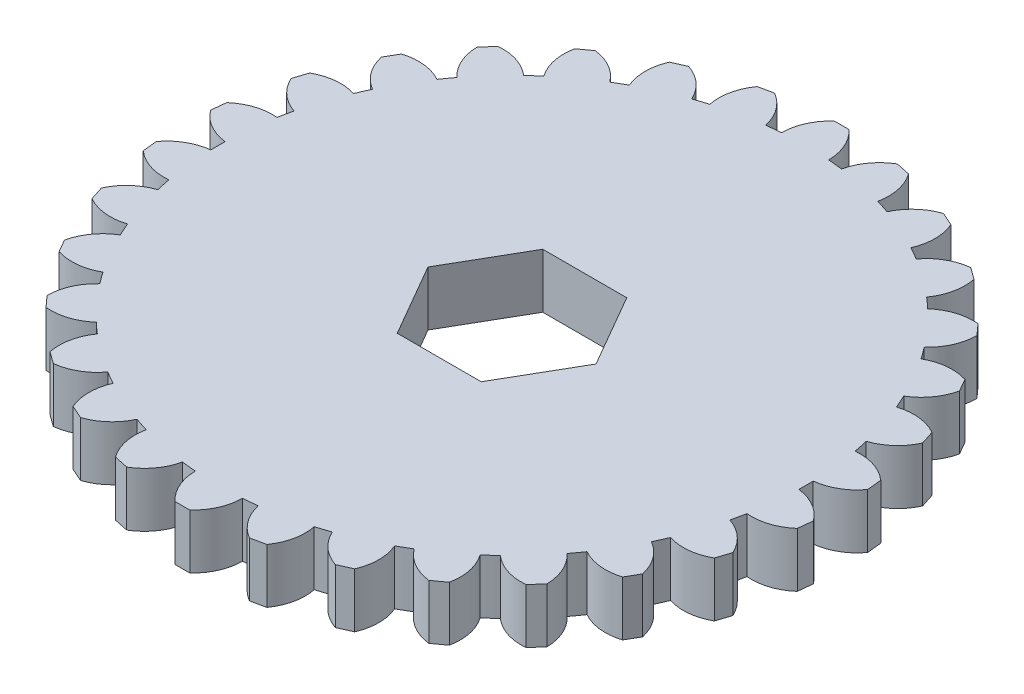
from build123d import *

# Parameters (mm, degrees)
SKETCH2_R           = 25.664173075
BOSS_EXTRUDE2_DEPTH = 4.7625
BOSS_EXTRUDE3_DEPTH = 4.7625
CIRPATTERN1_COUNT   = 30


with BuildPart() as part:
    # Sketch2 → Boss-Extrude2 (new body)
    with BuildSketch(Plane(origin=(0, 0, 0), x_dir=(1, 0, 0), z_dir=(0, 1, 0))):
        Circle(SKETCH2_R)
        Polygon((7.332348419, 0), (3.666174209, 6.35), (-3.666174209, 6.35), (-7.332348419, 0), (-3.666174209, -6.35), (3.666174209, -6.35), align=None, mode=Mode.SUBTRACT)
    extrude(amount=BOSS_EXTRUDE2_DEPTH)

    # Sketch1 → Boss-Extrude3 (add)
    with BuildSketch(Plane(origin=(0, 0, 0), x_dir=(1, 0, 0), z_dir=(0, 1, 0))):
        with BuildLine():
            Line((0.640211275, 28.764979636), (-0.640211275, 28.764979636))
            ThreePointArc((-0.640211275, 28.764979636), (-1.726312193, 27.213866774), (-2.055125292, 25.349075026))
            ThreePointArc((-2.055125292, 25.349075026), (0, 25.432246157), (2.055125292, 25.349075026))
            ThreePointArc((2.055125292, 25.349075026), (1.726312193, 27.213866774), (0.640211275, 28.764979636))
        make_face()
    boss_extrude3 = extrude(amount=BOSS_EXTRUDE3_DEPTH)

    # CirPattern1: Boss-Extrude3 ×30 about axis
    cirpattern1_axis = Axis((0, 0, 0), (0, 1, 0))
    for i in range(1, CIRPATTERN1_COUNT):
        add(boss_extrude3.rotate(cirpattern1_axis, i * 360 / CIRPATTERN1_COUNT))


solid = part.part
